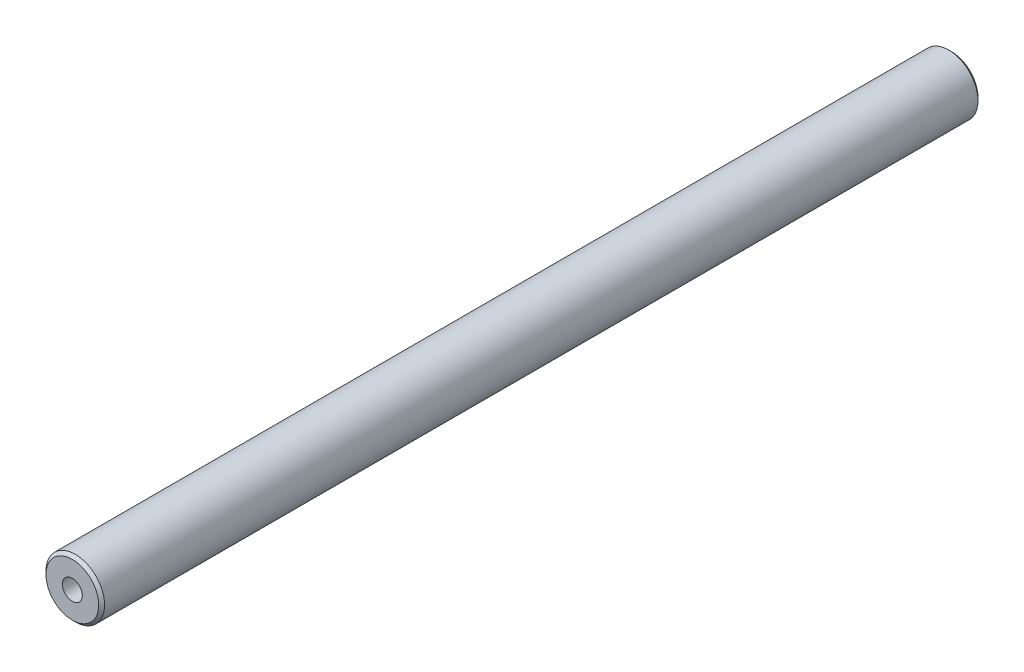
from build123d import *

# Parameters (mm, degrees)
SKETCH1_R             = 10
BOSS_EXTRUDE1_DEPTH   = 150
M8_TAPPED_HOLE1_D     = 6.8
M8_TAPPED_HOLE1_DEPTH = 19.75
M8_TAPPED_HOLE1_TIP   = 2.042926105
CHAMFER1_SIZE         = 1


with BuildPart() as part:
    # Sketch1 → Boss-Extrude1 (new body, symmetric)
    with BuildSketch(Plane.XY):
        Circle(SKETCH1_R)
    extrude(amount=BOSS_EXTRUDE1_DEPTH, both=True)

    # M8 Tapped Hole1
    with Locations(Plane.XY.offset(150)):
        with Locations((0, 0)):
            Hole(M8_TAPPED_HOLE1_D / 2, depth=M8_TAPPED_HOLE1_DEPTH)
            with Locations((0, 0, -(M8_TAPPED_HOLE1_DEPTH + M8_TAPPED_HOLE1_TIP / 2))):  # 118° drill point
                Cone(0, M8_TAPPED_HOLE1_D / 2, M8_TAPPED_HOLE1_TIP, mode=Mode.SUBTRACT)

    # Chamfer1
    chamfer1_edges = [part.edges().sort_by_distance(p)[0] for p in [
        (-10, 0, -150),
        (-10, 0, 150),
    ]]
    chamfer(chamfer1_edges, length=CHAMFER1_SIZE)


solid = part.part
